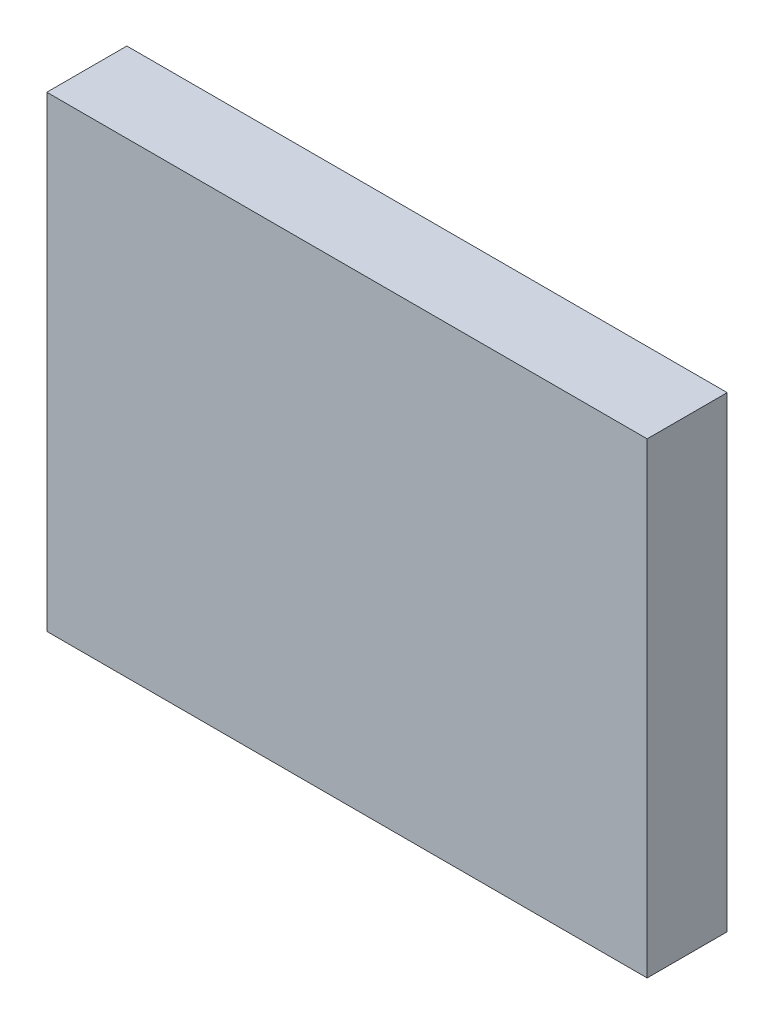
from build123d import *

# Parameters (mm, degrees)
SKETCH1_W           = 9
SKETCH1_H           = 7
BOSS_EXTRUDE1_DEPTH = 1.2


with BuildPart() as part:
    # Sketch1 → Boss-Extrude1 (new body)
    with BuildSketch(Plane.XY):
        Rectangle(SKETCH1_W, SKETCH1_H)
    extrude(amount=BOSS_EXTRUDE1_DEPTH)


solid = part.part
